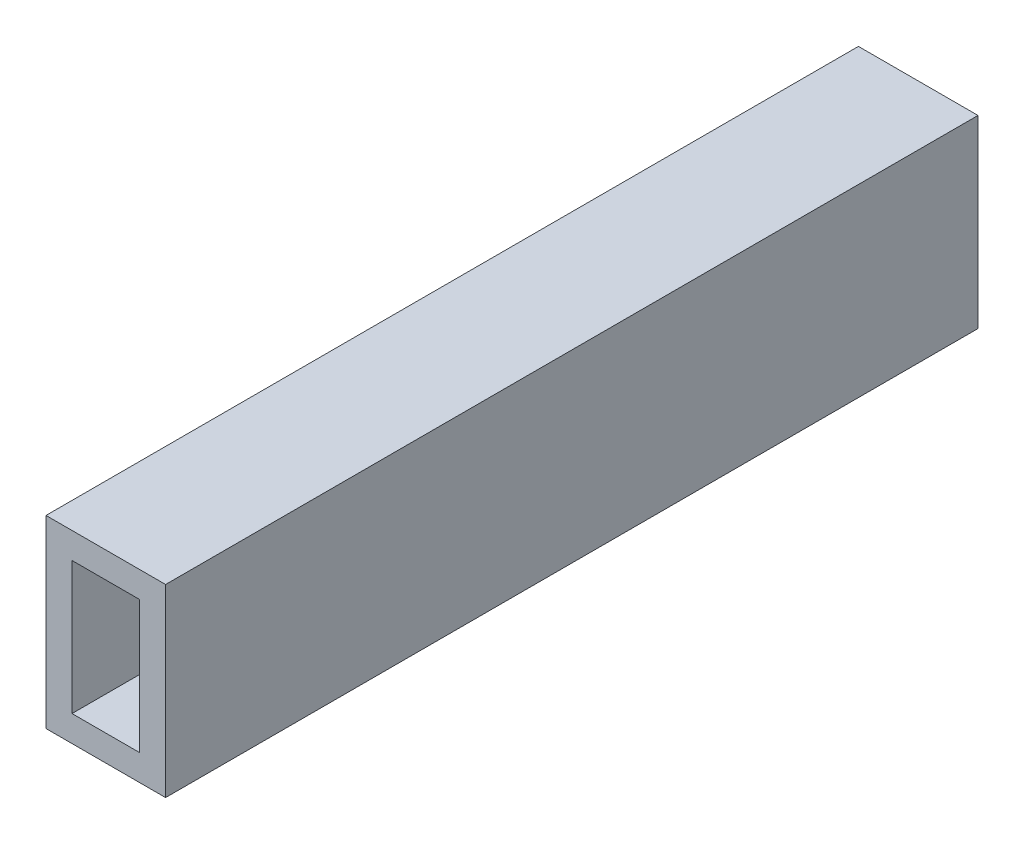
from build123d import *

# Parameters (mm, degrees)
SKETCH1_W           = 4.6
SKETCH1_H           = 7.1
SKETCH1_W_2         = 2.6
SKETCH1_H_2         = 5.1
BOSS_EXTRUDE1_DEPTH = 31.25


with BuildPart() as part:
    # Sketch1 → Boss-Extrude1 (new body)
    with BuildSketch(Plane.XY):
        Rectangle(SKETCH1_W, SKETCH1_H)
        Rectangle(SKETCH1_W_2, SKETCH1_H_2, mode=Mode.SUBTRACT)
    extrude(amount=BOSS_EXTRUDE1_DEPTH)


solid = part.part
